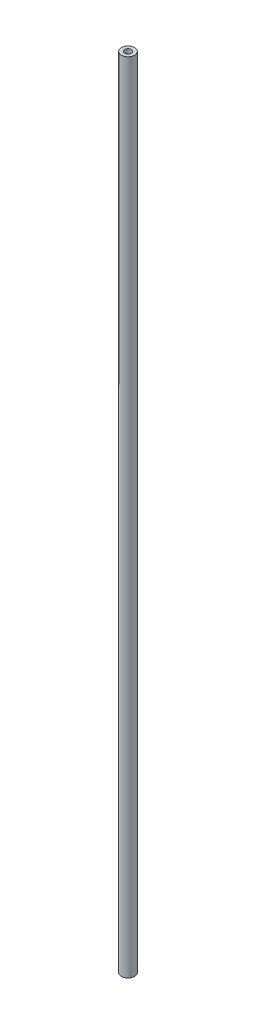
from build123d import *

# Parameters (mm, degrees)
SKETCH1_R           = 25.4
SKETCH1_R_2         = 12.7
BOSS_EXTRUDE1_DEPTH = 3070.098


with BuildPart() as part:
    # Sketch1 → Boss-Extrude1 (new body)
    with BuildSketch(Plane(origin=(0, 0, 0), x_dir=(1, 0, 0), z_dir=(0, 1, 0))):
        Circle(SKETCH1_R)
        Circle(SKETCH1_R_2, mode=Mode.SUBTRACT)
    extrude(amount=BOSS_EXTRUDE1_DEPTH)


solid = part.part
